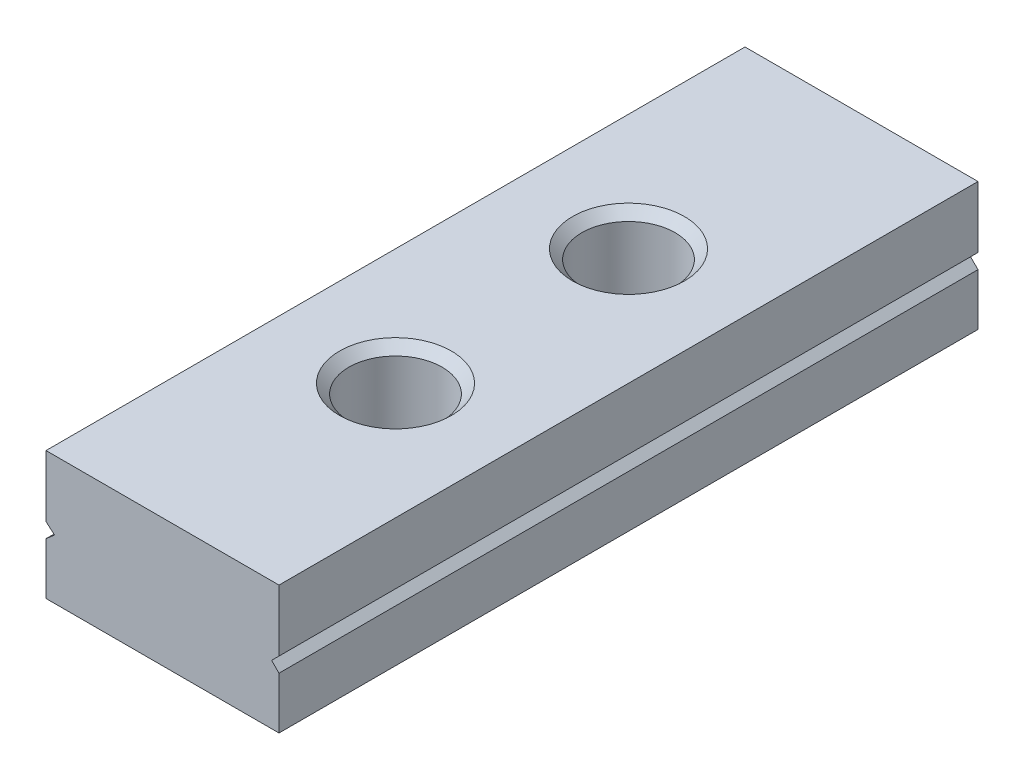
from build123d import *

# Parameters (mm, degrees)
SKETCH_1_W          = 5
SKETCH_1_H          = 15
EXTRUDE_1_DEPTH     = 2.75
SKETCH_2_R          = 1
CUT_EXTRUDE_1_DEPTH = 3.75
CUT_EXTRUDE_2_DEPTH = 16
CHAMFER_1_SIZE      = 0.2


with BuildPart() as part:
    # 草图1 → 凸台-拉伸1 (new body)
    with BuildSketch(Plane(origin=(0, 0, 0), x_dir=(1, 0, 0), z_dir=(0, 1, 0))):
        with Locations((2.5, -7.5)):
            Rectangle(SKETCH_1_W, SKETCH_1_H)
    extrude(amount=EXTRUDE_1_DEPTH)

    # 草图2 → 切除-拉伸1 (cut, through all)
    with BuildSketch(Plane(origin=(0, 0, 0), x_dir=(-1, 0, 0), z_dir=(0, -1, 0))):
        with Locations((-2.5, -10)):
            Circle(SKETCH_2_R)
        with Locations((-2.5, -5)):
            Circle(SKETCH_2_R)
    extrude(amount=-CUT_EXTRUDE_1_DEPTH, mode=Mode.SUBTRACT)

    # 草图3 → 切除-拉伸2 (cut, through all)
    with BuildSketch(Plane(origin=(0, 0, 0), x_dir=(-1, 0, 0), z_dir=(0, 0, -1))):
        Polygon((0, 1.112237097), (-0.183390928, 1.271215949), (0, 1.430194801), align=None)
        Polygon((-5, 1.112237097), (-4.841021148, 1.271215949), (-5, 1.430194801), align=None)
    extrude(amount=-CUT_EXTRUDE_2_DEPTH, mode=Mode.SUBTRACT)

    # 倒角1
    chamfer_1_edges = [part.edges().sort_by_distance(p)[0] for p in [
        (3.5, 2.75, 10),
        (3.5, 2.75, 5),
    ]]
    chamfer(chamfer_1_edges, length=CHAMFER_1_SIZE)


solid = part.part
